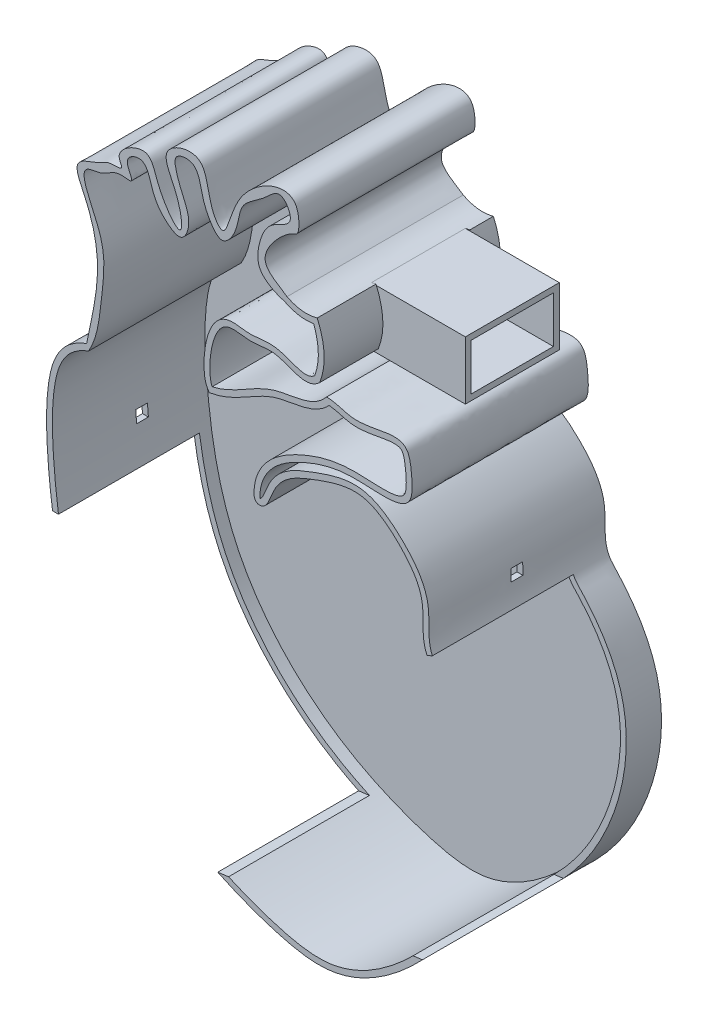
from build123d import *

# Parameters (mm, degrees)
BOSS_EXTRUDE1_DEPTH = 5.08
BOSS_EXTRUDE2_DEPTH = 38.1
CUT_EXTRUDE1_DEPTH  = 38.1
SKETCH6_W           = 2.54
SKETCH6_H           = 2.54
CUT_EXTRUDE3_DEPTH  = 38.1
SKETCH5_W           = 2.54
SKETCH5_H           = 2.54
CUT_EXTRUDE4_DEPTH  = 38.1
SKETCH8_W           = 11.462792648
SKETCH8_H           = 14.427472703
CUT_EXTRUDE5_DEPTH  = 20.32
SKETCH9_W           = 20.32
SKETCH9_H           = 12.603335188
SKETCH9_W_2         = 17.78
SKETCH9_H_2         = 10.063335188
BOSS_EXTRUDE4_DEPTH = 20.32


with BuildPart() as part:
    # Sketch1 → Boss-Extrude1 (new body)
    with BuildSketch(Plane.XY):
        with BuildLine():
            add(Edge.make_bspline(
                [(163.90826608, 338.103886368), (161.976810342, 337.441244138), (157.10288206, 334.254340359), (154.91024519, 324.319782797), (155.574673987, 306.96233458), (159.33516627, 282.896468341), (178.216271, 259.818321197), (198.545279867, 249.618361545), (218.657994732, 245.023183274), (234.970537313, 255.628943236), (248.357422291, 273.771705937), (252.561955643, 297.43001675), (244.028678123, 311.069677228), (237.144090145, 318.088781455), (239.256301818, 326.952241756), (232.879615346, 335.433998963), (223.655666953, 342.294025632), (212.282262929, 338.397485802), (203.996528427, 334.961514589), (202.073443035, 328.141447917), (201.373028976, 327.787797319)],
                knots=[0, 0, 0, 0, 0.018355702, 0.050112896, 0.089989003, 0.184833858, 0.273021776, 0.359649237, 0.397816634, 0.461195161, 0.526426676, 0.612455038, 0.666069007, 0.672633998, 0.703549792, 0.738354084, 0.768396491, 0.80457234, 0.842170891, 0.854276137, 0.854276137, 0.854276137, 0.854276137], degree=3))
            add(Edge.make_bspline(
                [(201.373028976, 327.787797319), (201.24112925, 334.1721396), (210.096067449, 339.7603273), (221.549405848, 342.729253479), (234.609106196, 340.355249251), (234.308220802, 348.413952834), (233.134733858, 356.582141616), (224.419660614, 351.828676435), (218.609160937, 353.657757203), (216.10387106, 354.182034753), (215.747901037, 353.962830093), (215.711502791, 353.949051852)],
                knots=[0, 0, 0, 0, 0.064969659, 0.106571574, 0.152532462, 0.172855564, 0.189446858, 0.237485795, 0.244272407, 0.257312975, 0.25877111, 0.25877111, 0.25877111, 0.25877111], degree=3))
            add(Edge.make_bspline(
                [(191.056455799, 343.591270719), (195.873942438, 344.57511546), (203.01909477, 351.299772922), (212.746820023, 350.337323345), (215.711502791, 353.949051852)],
                knots=[0, 0, 0, 0, 0.545988298, 1, 1, 1, 1], degree=3))
            add(Edge.make_bspline(
                [(191.056455799, 343.591270719), (189.953223697, 345.589458273), (190.632915902, 358.363210826), (199.387799422, 355.785728046), (206.01476934, 357.780486156), (211.195334161, 353.056058065), (214.308215173, 355.986546636)],
                knots=[0, 0, 0, 0, 0.405824065, 0.536970146, 0.698075437, 1, 1, 1, 1], degree=3))
            add(Edge.make_bspline(
                [(214.308215173, 355.986546636), (216.501017547, 361.6168408), (213.771012714, 367.819098329)],
                knots=[0, 0, 0, 1, 1, 1], degree=2))
            add(Edge.make_bspline(
                [(207.245879865, 368.548652275), (210.427912159, 366.91826851), (213.771012714, 367.819098329)],
                knots=[0, 0, 0, 1, 1, 1], degree=2))
            add(Edge.make_bspline(
                [(207.245879865, 368.548652275), (205.059782029, 370.020960749), (199.531678786, 372.805714922), (208.01581893, 381.652967887), (209.981691359, 380.855465042), (209.699498585, 391.199651342), (195.494576841, 384.74383643), (194.227298212, 371.497005993), (189.944141857, 377.948495499), (190.053345559, 387.233601082), (178.706840309, 383.430036514), (183.986704675, 376.012214528), (185.367561401, 366.169695343), (178.92788534, 374.968930446), (177.772229204, 382.458634504), (169.352824509, 377.558766705), (172.507651074, 374.20308167), (168.696992034, 374.726466671), (166.011986596, 372.762384819), (160.207185162, 371.621291761), (168.516959755, 356.861518308), (166.028244832, 348.522154021), (163.90826608, 338.103886368)],
                knots=[0.325249583, 0.325249583, 0.325249583, 0.325249583, 0.355330235, 0.400071433, 0.424305589, 0.445546093, 0.499592027, 0.537542922, 0.556664967, 0.593446954, 0.62802155, 0.659335998, 0.693837299, 0.72858292, 0.755386645, 0.783228762, 0.795801527, 0.810718916, 0.820629886, 0.845085754, 0.871446486, 1, 1, 1, 1], degree=3))
        make_face()
    extrude(amount=BOSS_EXTRUDE1_DEPTH)

    # Sketch1_6 → Boss-Extrude2 (add)
    with BuildSketch(Plane.XY):
        with BuildLine():
            add(Edge.make_bspline(
                [(207.245879865, 368.548652275), (205.059782029, 370.020960749), (199.531678786, 372.805714922), (208.01581893, 381.652967887), (209.981691359, 380.855465042), (209.699498585, 391.199651342), (195.494576841, 384.74383643), (194.227298212, 371.497005993), (189.944141857, 377.948495499), (190.053345559, 387.233601082), (178.706840309, 383.430036514), (183.986704675, 376.012214528), (185.367561401, 366.169695343), (178.92788534, 374.968930446), (177.772229204, 382.458634504), (169.352824509, 377.558766705), (172.507651074, 374.20308167), (168.696992034, 374.726466671), (166.011986596, 372.762384819), (160.207185162, 371.621291761), (168.516959755, 356.861518308), (166.028244832, 348.522154021), (163.90826608, 338.103886368)],
                knots=[0.325249583, 0.325249583, 0.325249583, 0.325249583, 0.355330235, 0.400071433, 0.424305589, 0.445546093, 0.499592027, 0.537542922, 0.556664967, 0.593446954, 0.62802155, 0.659335998, 0.693837299, 0.72858292, 0.755386645, 0.783228762, 0.795801527, 0.810718916, 0.820629886, 0.845085754, 0.871446486, 1, 1, 1, 1], degree=3))
            add(Edge.make_bspline(
                [(163.90826608, 338.103886368), (161.976810342, 337.441244138), (157.10288206, 334.254340359), (154.91024519, 324.319782797), (155.574673987, 306.96233458), (159.33516627, 282.896468341), (178.216271, 259.818321197), (198.545279867, 249.618361545), (218.657994732, 245.023183274), (234.970537313, 255.628943236), (248.357422291, 273.771705937), (252.561955643, 297.43001675), (244.028678123, 311.069677228), (237.144090145, 318.088781455), (239.256301818, 326.952241756), (232.879615346, 335.433998963), (223.655666953, 342.294025632), (212.282262929, 338.397485802), (203.996528427, 334.961514589), (202.073443035, 328.141447917), (201.373028976, 327.787797319)],
                knots=[0, 0, 0, 0, 0.018355702, 0.050112896, 0.089989003, 0.184833858, 0.273021776, 0.359649237, 0.397816634, 0.461195161, 0.526426676, 0.612455038, 0.666069007, 0.672633998, 0.703549792, 0.738354084, 0.768396491, 0.80457234, 0.842170891, 0.854276137, 0.854276137, 0.854276137, 0.854276137], degree=3))
            add(Edge.make_bspline(
                [(201.373028976, 327.787797319), (201.24112925, 334.1721396), (210.096067449, 339.7603273), (221.549405848, 342.729253479), (234.609106196, 340.355249251), (234.308220802, 348.413952834), (233.134733858, 356.582141616), (224.419660614, 351.828676435), (218.609160937, 353.657757203), (216.10387106, 354.182034753), (215.747901037, 353.962830093), (215.711502791, 353.949051852)],
                knots=[0, 0, 0, 0, 0.064969659, 0.106571574, 0.152532462, 0.172855564, 0.189446858, 0.237485795, 0.244272407, 0.257312975, 0.25877111, 0.25877111, 0.25877111, 0.25877111], degree=3))
            add(Edge.make_bspline(
                [(191.056455799, 343.591270719), (195.873942438, 344.57511546), (203.01909477, 351.299772922), (212.746820023, 350.337323345), (215.711502791, 353.949051852)],
                knots=[0, 0, 0, 0, 0.545988298, 1, 1, 1, 1], degree=3))
            add(Edge.make_bspline(
                [(191.056455799, 343.591270719), (189.953223697, 345.589458273), (190.632915902, 358.363210826), (199.387799422, 355.785728046), (205.921614217, 357.7524459), (211.00844135, 353.22445718), (214.049271861, 355.756959898)],
                knots=[0, 0, 0, 0, 0.405824065, 0.536970146, 0.698075437, 0.991647686, 0.991647686, 0.991647686, 0.991647686], degree=3))
            add(Edge.make_bspline(
                [(214.308215173, 355.986546636), (214.177849125, 355.870994269), (214.049271861, 355.756959898)],
                knots=[0, 0, 0, 0.004863462, 0.004863462, 0.004863462], degree=2))
            add(Edge.make_bspline(
                [(214.308215173, 355.986546636), (216.501017547, 361.6168408), (213.771012714, 367.819098329)],
                knots=[0, 0, 0, 1, 1, 1], degree=2))
            add(Edge.make_bspline(
                [(207.245879865, 368.548652275), (210.427912159, 366.91826851), (213.771012714, 367.819098329)],
                knots=[0, 0, 0, 1, 1, 1], degree=2))
        make_face()
        with BuildLine():
            add(Edge.make_bspline(
                [(213.230613234, 356.728430561), (213.826273025, 358.363592103), (214.072992185, 361.251655139), (213.743622582, 364.37542826), (212.998012602, 366.355818412)],
                knots=[0.027261532, 0.027261532, 0.027261532, 0.344218357, 0.573697262, 0.917915619, 0.917915619, 0.917915619], degree=2))
            add(Edge.make_bspline(
                [(213.230613234, 356.728430561), (213.168702494, 356.677095413), (212.97252817, 356.523317621), (212.548929073, 356.258558967), (211.962364448, 356.043419213), (211.220787821, 355.97799759), (210.083181531, 356.11713237), (208.401708053, 356.68682755), (206.502341448, 357.421963066), (204.811658676, 357.817142438), (203.054454595, 357.921508575), (201.500915369, 357.724831485), (200.048116015, 357.582940944), (199.036433029, 357.554998884), (197.969936056, 357.666677984), (196.758025285, 357.835576292), (195.482477744, 357.934314344), (194.072343973, 357.774875091), (192.756395996, 357.103422087), (191.76351454, 356.127236032), (190.991245716, 354.955852404), (190.200029202, 353.211748189), (189.564403369, 350.792040261), (189.294605127, 348.334505922), (189.267831482, 346.523253777), (189.338429929, 345.281869694), (189.470959198, 344.374493079), (189.635041746, 343.719940462), (189.764299535, 343.345855035), (189.892993952, 343.07092447), (189.962700337, 342.944761224), (190.001421033, 342.874607781), (190.060416274, 342.767765567), (190.193255952, 342.527158785), (190.306234044, 342.322534766), (190.395887442, 342.160153429)],
                knots=[-0.046532443, -0.046532443, -0.046532443, -0.046532443, -0.038838927, -0.02234942, 0.010629593, 0.043608607, 0.07658762, 0.142545647, 0.208503675, 0.241482688, 0.274461702, 0.340419729, 0.373398742, 0.406377756, 0.43935677, 0.472335783, 0.505314797, 0.53829381, 0.571272824, 0.604251837, 0.637230851, 0.670209864, 0.736167892, 0.802125919, 0.835104932, 0.868083946, 0.901062959, 0.917552466, 0.934041973, 0.942286726, 0.946409103, 0.95053148, 0.958776233, 0.967020986, 1, 1, 1, 1], degree=3))
            add(Edge.make_bspline(
                [(190.395887442, 342.160153429), (190.677084589, 342.217580539), (191.218771477, 342.323807627), (192.467804496, 342.605278856), (194.492776049, 343.288807206), (197.192733366, 344.624977993), (200.208266932, 346.383103489), (202.668773909, 347.656978551), (204.634556065, 348.388537096), (206.67932736, 348.89140659), (208.960393829, 349.224487853), (211.311122608, 349.750336229), (213.080464731, 350.356258213), (214.518029044, 351.141389398), (215.596483814, 351.981039195), (216.116304101, 352.490385398), (216.357083576, 352.75464031)],
                knots=[-0.034555261, -0.034555261, -0.034555261, -0.034555261, -0.002685873, 0.029183515, 0.092922292, 0.220399844, 0.347877397, 0.47535495, 0.539093726, 0.602832502, 0.730310055, 0.794048831, 0.857787608, 0.921526384, 0.953395772, 0.985265161, 0.985265161, 0.985265161, 0.985265161], degree=3))
            add(Edge.make_bspline(
                [(216.357083576, 352.75464031), (216.419314401, 352.748753135), (216.535430602, 352.735364371), (216.831380294, 352.69234281), (217.419949767, 352.584450146), (218.40006425, 352.357697257), (219.467987028, 352.050093025), (220.643549077, 351.744487076), (221.937042256, 351.617909762), (223.62115623, 351.653130978), (225.70513198, 351.946411509), (228.044233749, 352.402189774), (229.732873457, 352.643388866), (230.798490529, 352.646116348), (231.410841696, 352.549113854), (231.811432211, 352.376464097), (232.059173816, 352.17494224), (232.312830876, 351.778890593), (232.649634989, 350.808621864), (232.895715171, 349.066308367), (233.049395148, 347.169573927), (233.036180562, 345.87162091), (232.938415974, 345.037510928), (232.750302299, 344.401396111), (232.521594173, 344.014466222), (232.195787339, 343.698029801), (231.54943636, 343.321707383), (230.286529169, 342.988612508), (227.559429722, 342.83780365), (224.252931926, 343.077015983), (221.028631172, 343.111132608), (218.05329013, 342.882939868), (214.659131319, 342.173354896), (210.866051682, 340.771701309), (206.95585751, 338.881284116), (203.990091917, 336.694350571), (202.071958434, 334.457680336), (200.94764148, 332.510066219), (200.352122271, 330.651920351), (200.122056682, 329.046377268), (200.094550048, 328.185085229), (200.103299926, 327.761564873)],
                knots=[0, 0, 0, 0, 0.000990067, 0.001980135, 0.00396027, 0.00792054, 0.01188081, 0.01584108, 0.01980135, 0.02376162, 0.03168216, 0.0396027, 0.04752324, 0.05148351, 0.05544378, 0.05940405, 0.063364319, 0.067324589, 0.071284859, 0.079205399, 0.087125939, 0.091086209, 0.095046479, 0.099006749, 0.102967019, 0.106927289, 0.110887559, 0.118808099, 0.126728639, 0.142569719, 0.150490259, 0.158410799, 0.174251879, 0.190092958, 0.205934038, 0.221775118, 0.229695658, 0.237616198, 0.245536738, 0.249497008, 0.253457278, 0.253457278, 0.253457278, 0.253457278], degree=3))
            add(Edge.make_bspline(
                [(200.103299926, 327.761564873), (200.430514043, 326.153455961), (201.945444851, 326.65411303)],
                knots=[0, 0, 0, 1, 1, 1], degree=2))
            add(Edge.make_bspline(
                [(164.320396623, 336.902616866), (163.073998964, 336.475003793), (160.654019087, 335.112257127), (158.365433732, 332.153797864), (157.14467079, 328.347452552), (156.608837612, 324.122553549), (156.434198736, 319.97959779), (156.550346587, 315.843180044), (156.840908267, 311.665318754), (157.360317718, 306.061014217), (158.355871383, 299.080701763), (160.321083308, 290.913166301), (163.279855935, 283.148032192), (167.449905969, 275.905779028), (172.645187915, 269.284205733), (178.684247744, 263.413446632), (185.366269791, 258.430739629), (192.611324417, 254.324113381), (199.059432773, 251.601280704), (204.44849746, 249.817852848), (208.549127268, 248.69685439), (212.600395114, 248.049407275), (216.498285809, 248.103338092), (220.319641102, 249.020208445), (225.315168755, 251.190039851), (230.032436433, 254.525248797), (234.254437489, 258.389316706), (238.078436452, 262.458322646), (242.127888501, 267.990545943), (245.856520475, 275.459708959), (248.354674144, 283.691768493), (249.064176778, 290.708095945), (248.641879152, 296.177359067), (247.788865264, 300.139324226), (246.359602142, 303.941318621), (244.744629287, 306.965900181), (243.232298078, 309.280216462), (241.99639764, 310.960298879), (240.890465817, 312.307514), (239.96184641, 313.35793918), (239.251779895, 314.115083613), (238.463881093, 314.95656816), (237.724392811, 316.008287509), (237.232855635, 317.13477386), (236.82088135, 318.672089008), (236.651389477, 320.609760934), (236.660905423, 322.881268268), (236.6302112, 325.024291029), (236.224983061, 327.521428943), (234.879893753, 330.435227411), (232.261084948, 333.637002763), (229.067455009, 336.616159592), (225.669640442, 338.799968517), (222.251568731, 339.589958222), (218.364712517, 339.047169003), (214.941012357, 337.906359616), (212.188852234, 336.874962226), (210.250733722, 336.090841592), (208.484108941, 335.195170859), (206.925719619, 334.123038202), (205.589267107, 332.789734537), (204.658965791, 331.387211034), (204.036065062, 329.984185139), (203.642571275, 328.98250035), (203.295176743, 328.215693084), (202.995984237, 327.663183592), (202.67214015, 327.216728132), (202.315721337, 326.877947187), (202.070278672, 326.717143683), (201.945444851, 326.65411303)],
                knots=[0, 0, 0, 0, 0.013348065, 0.026696129, 0.040044194, 0.053392259, 0.066740323, 0.080088388, 0.093436452, 0.106784517, 0.133480646, 0.160176776, 0.186872905, 0.213569034, 0.240265163, 0.266961293, 0.293657422, 0.320353551, 0.347049681, 0.360397745, 0.37374581, 0.387093874, 0.400441939, 0.413790004, 0.427138068, 0.453834198, 0.467182262, 0.480530327, 0.507226456, 0.533922586, 0.560618715, 0.587314844, 0.600662909, 0.614010973, 0.627359038, 0.640707103, 0.647381135, 0.654055167, 0.6607292, 0.664066216, 0.667403232, 0.670740248, 0.674077264, 0.67741428, 0.680751297, 0.687425329, 0.694099361, 0.700773393, 0.707447426, 0.72079549, 0.734143555, 0.74749162, 0.760839684, 0.774187749, 0.787535814, 0.800883878, 0.807557911, 0.814231943, 0.820905975, 0.827580008, 0.83425404, 0.840928072, 0.844265088, 0.847602105, 0.849270613, 0.850939121, 0.852607629, 0.853441883, 0.854276137, 0.854276137, 0.854276137, 0.854276137], degree=3))
            add(Edge.make_bspline(
                [(164.320396623, 336.902616866), (166.244809985, 340.24106306), (166.869579017, 346.461915836), (168.079171152, 355.647101586), (166.322543957, 362.330633957), (161.423811838, 371.138481693), (167.874090929, 371.302480177), (169.855916972, 373.991532397), (174.908242408, 372.760933034), (171.167917582, 377.11278926), (176.61168093, 379.565612183), (178.024973365, 373.599386451), (179.938254556, 370.175953822), (184.539429077, 367.164490625), (186.646561674, 371.790213745), (184.899910746, 375.842435225), (183.368214301, 379.31298771), (182.620140397, 383.359153495), (187.728295164, 384.112441285), (188.695618567, 378.929793305), (189.793210041, 375.354821316), (193.112503368, 370.734946427), (196.895323948, 375.614512834), (196.625751358, 381.37938876), (201.886832377, 383.684221601), (205.900338934, 388.453547484), (209.425279718, 382.351056673), (203.341258766, 380.880259674), (201.185104681, 376.293237067), (200.343658288, 369.939328748), (204.824741075, 367.912820329), (206.66675928, 367.41837826)],
                knots=[0, 0, 0, 0, 0.076998944, 0.134833216, 0.184407435, 0.24356582, 0.261661453, 0.297591274, 0.312369058, 0.336081285, 0.359360448, 0.389531953, 0.433791699, 0.456295318, 0.478514721, 0.514098283, 0.547063136, 0.563354597, 0.587316901, 0.618087072, 0.652890058, 0.679695029, 0.706126934, 0.74903967, 0.794104971, 0.821074457, 0.850118251, 0.880461284, 0.920008059, 0.954845985, 1, 1, 1, 1], degree=3))
            add(Edge.make_bspline(
                [(212.998012602, 366.355818412), (209.728700583, 365.844230936), (206.66675928, 367.41837826)],
                knots=[0, 0, 0, 0.853874735, 0.853874735, 0.853874735], degree=2))
        make_face(mode=Mode.SUBTRACT)
    extrude(amount=BOSS_EXTRUDE2_DEPTH)

    # Sketch3 → Cut-Extrude1 (cut)
    with BuildSketch(Plane.XY.offset(7.62)):
        Polygon((154.398580983, 303.078287936), (165.058405534, 303.078287936), (226.473531077, 313.779698986), (233.73911115, 314.683301989), (238.689966014, 317.000233831), (245.836217621, 320.344581091), (268.870560545, 294.155931061), (260.247209898, 270.936390357), (242.942266456, 259.815513483), (190.258040667, 253.002202647), (163.542287761, 255.737428772), (142.191628258, 294.155931061), align=None)
    extrude(amount=CUT_EXTRUDE1_DEPTH, mode=Mode.SUBTRACT)

    # Sketch6 → Cut-Extrude3 (cut)
    with BuildSketch(Plane(origin=(231.14, 0, 0), x_dir=(0, 0, -1), z_dir=(1, 0, 0))):
        with Locations((-19.05, 322.81151024)):
            Rectangle(SKETCH6_W, SKETCH6_H)
    extrude(amount=CUT_EXTRUDE3_DEPTH, mode=Mode.SUBTRACT)

    # Sketch5 → Cut-Extrude4 (cut)
    with BuildSketch(Plane(origin=(160.02, 0, 0), x_dir=(0, 0, -1), z_dir=(1, 0, 0))):
        with Locations((-19.05, 311.968287956)):
            Rectangle(SKETCH5_W, SKETCH5_H)
    extrude(amount=-CUT_EXTRUDE4_DEPTH, mode=Mode.SUBTRACT)

    # Sketch8 → Cut-Extrude5 (cut)
    with BuildSketch(Plane.XY.offset(5.08)):
        with Locations((218.52667032, 362.014383264)):
            Rectangle(SKETCH8_W, SKETCH8_H)
    extrude(amount=CUT_EXTRUDE5_DEPTH, mode=Mode.SUBTRACT)

    # Sketch9 → Boss-Extrude4 (add)
    with BuildSketch(Plane(origin=(212.795273996, 0, 0), x_dir=(0, 0, -1), z_dir=(1, 0, 0))):
        with Locations((-15.24, 361.307866288)):
            Rectangle(SKETCH9_W, SKETCH9_H)
        with Locations((-15.24, 361.307866288)):
            Rectangle(SKETCH9_W_2, SKETCH9_H_2, mode=Mode.SUBTRACT)
    extrude(amount=BOSS_EXTRUDE4_DEPTH)


solid = part.part
